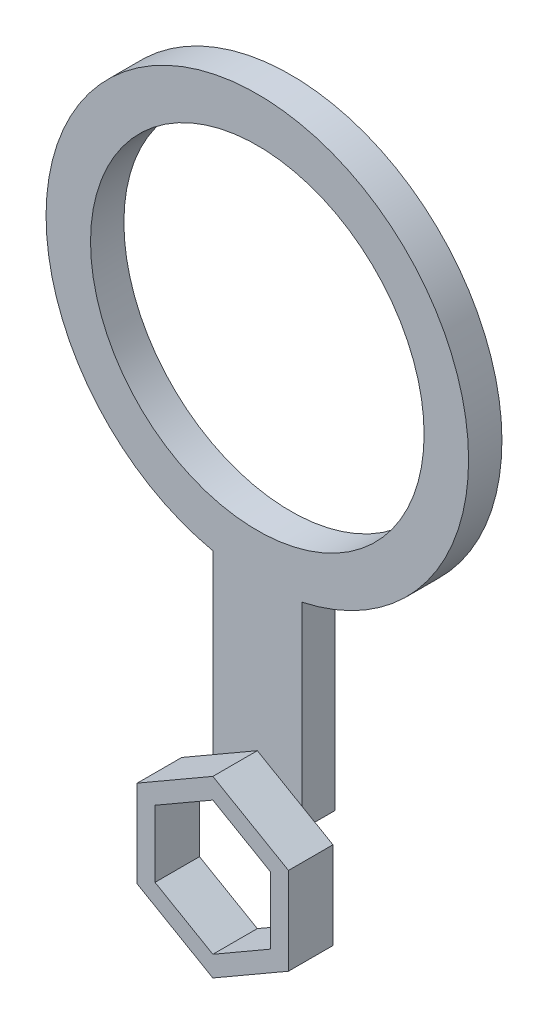
from build123d import *

# Parameters (mm, degrees)
SKETCH1_R           = 19
SKETCH1_R_2         = 15
BOSS_EXTRUDE1_DEPTH = 3
BOSS_EXTRUDE2_DEPTH = 4
CUT_EXTRUDE1_DEPTH  = 4


with BuildPart() as part:
    # Sketch1 → Boss-Extrude1 (new body)
    with BuildSketch(Plane.XY):
        Polygon((5, -2.886751346), (5, 2.886751346), (0, 5.773502692), (-5, 2.886751346), (-5, -2.886751346), (0, -5.773502692), align=None)
        with BuildLine():
            Line((-4, 3.464101615), (0, 5.773502692))
            Line((0, 5.773502692), (4, 3.464101615))
            Line((4, 3.464101615), (4, 21.425824379))
            ThreePointArc((4, 21.425824379), (0, 21), (-4, 21.425824379))
            Line((-4, 21.425824379), (-4, 3.464101615))
        make_face()
        with Locations((0, 40)):
            Circle(SKETCH1_R)
        with Locations((0, 40)):
            Circle(SKETCH1_R_2, mode=Mode.SUBTRACT)
    extrude(amount=BOSS_EXTRUDE1_DEPTH)

    # Sketch2 → Boss-Extrude2 (add)
    with BuildSketch(Plane.XY.offset(3)):
        Polygon((0, -7.851963661), (6.8, -3.92598183), (6.8, 3.92598183), (0, 7.851963661), (-6.8, 3.92598183), (-6.8, -3.92598183), align=None)
        Polygon((0, -6.0044428), (5.2, -3.0022214), (5.2, 3.0022214), (0, 6.0044428), (-5.2, 3.0022214), (-5.2, -3.0022214), align=None, mode=Mode.SUBTRACT)
    extrude(amount=BOSS_EXTRUDE2_DEPTH)

    # Sketch3 → Cut-Extrude1 (cut, through all)
    with BuildSketch(Plane.XY.offset(3)):
        Polygon((4, 3.464101615), (4, 3.695041723), (0, 6.0044428), (-4, 3.695041723), (-4, 3.464101615), (-5, 2.886751346), (-5, -2.886751346), (0, -5.773502692), (5, -2.886751346), (5, 2.886751346), align=None)
    extrude(amount=-CUT_EXTRUDE1_DEPTH, mode=Mode.SUBTRACT)


solid = part.part
